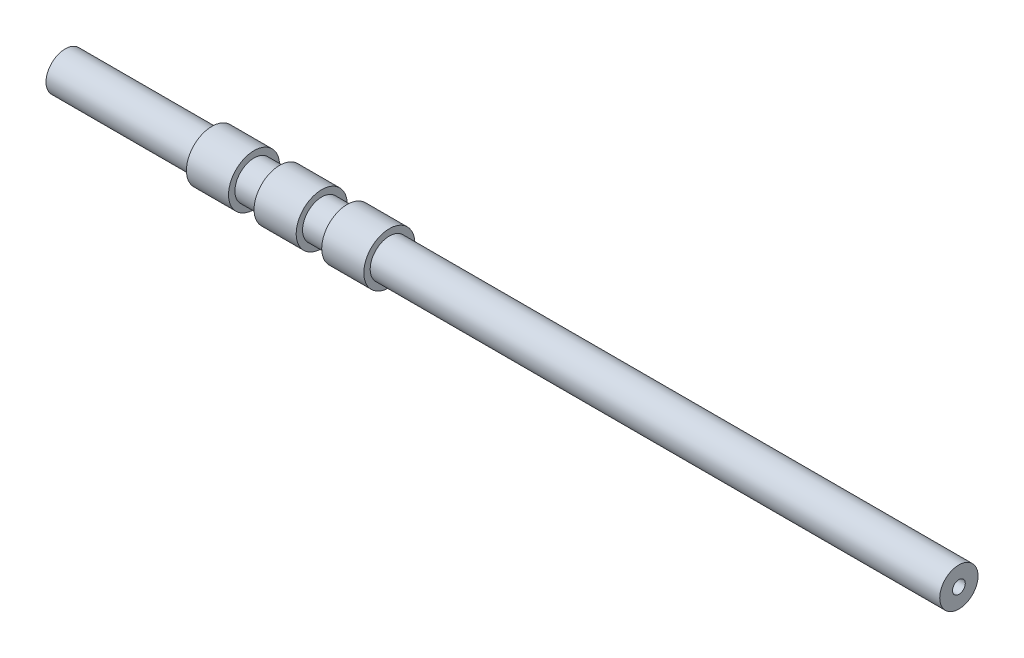
from build123d import *


with BuildPart() as part:
    # Sketch1 → Revolve-Thin1 (revolve)
    with BuildSketch(Plane.XY):
        Polygon((-177.698412698, 15), (-152.698412698, 15), (-62.698412698, 15), (-62.698412698, 20), (-29.728412698, 20), (-29.728412698, 15), (-9.728412698, 15), (-9.728412698, 20), (23.241587302, 20), (23.241587302, 15), (43.241587302, 15), (43.241587302, 20), (76.211587302, 20), (76.211587302, 15), (192.237786857, 15), (497.301587302, 15), (522.301587302, 15), (522.301587302, 5), (497.301587302, 5), (192.237786857, 5), (66.211587302, 5), (66.211587302, 10), (53.241587302, 10), (53.241587302, 5), (13.241587302, 5), (13.241587302, 10), (0.271587302, 10), (0.271587302, 5), (-39.728412698, 5), (-39.728412698, 10), (-52.698412698, 10), (-52.698412698, 5), (-152.698412698, 5), (-177.698412698, 5), align=None)
    revolve(axis=Axis((-114.603174603, 0, 0), (1, 0, 0)))


solid = part.part
